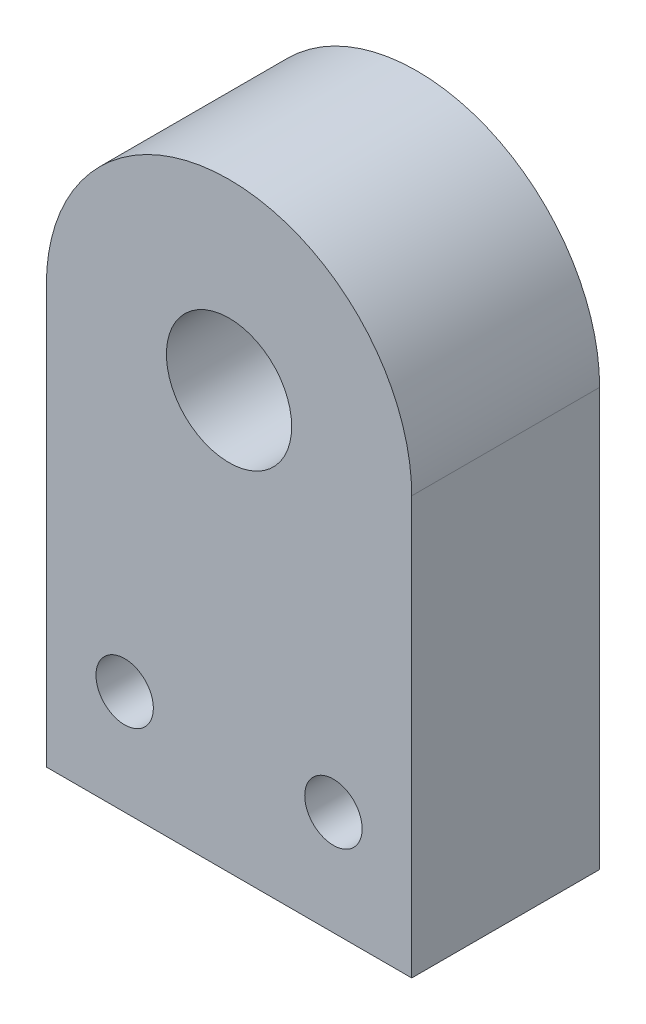
from build123d import *

# Parameters (mm, degrees)
SKETCH_1_R      = 6
SKETCH_1_R_2    = 2.75
EXTRUDE_1_DEPTH = 18


with BuildPart() as part:
    # 草图1 → 凸台-拉伸1 (new body)
    with BuildSketch(Plane.XY):
        with BuildLine():
            Line((-17.5, 0), (-17.5, -40))
            Line((-17.5, -40), (17.5, -40))
            Line((17.5, -40), (17.5, 0))
            ThreePointArc((17.5, 0), (0, 17.5), (-17.5, 0))
        make_face()
        Circle(SKETCH_1_R, mode=Mode.SUBTRACT)
        with Locations((-10, -30)):
            Circle(SKETCH_1_R_2, mode=Mode.SUBTRACT)
        with Locations((10, -30)):
            Circle(SKETCH_1_R_2, mode=Mode.SUBTRACT)
    extrude(amount=EXTRUDE_1_DEPTH)


solid = part.part
